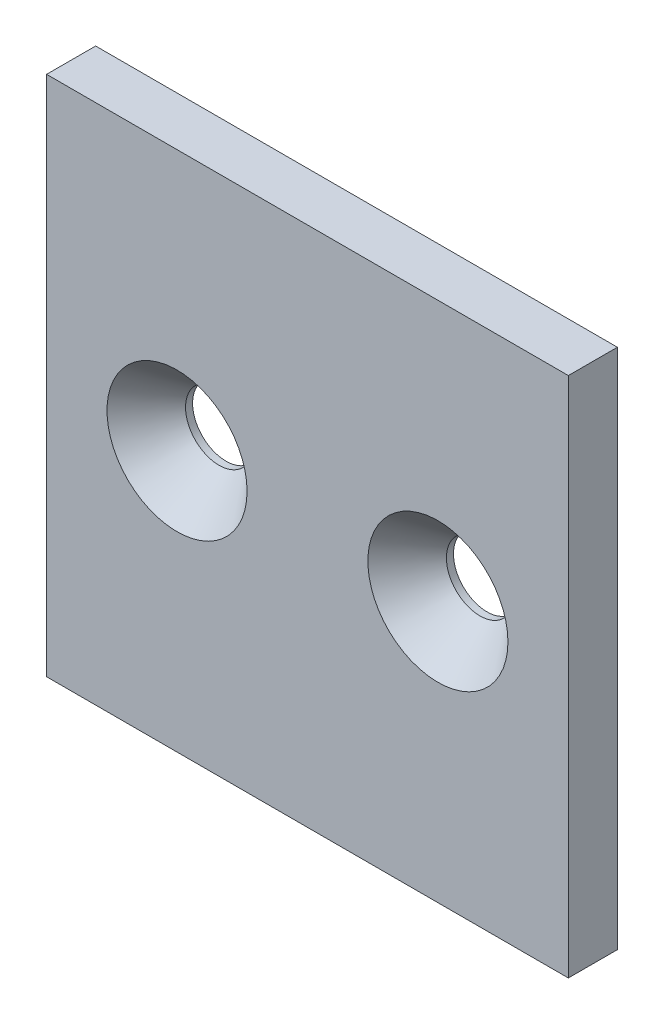
from build123d import *

# Parameters (mm, degrees)
SKETCH1_W           = 50.8
SKETCH1_H           = 50.8
SKETCH1_R           = 3.2639
BOSS_EXTRUDE1_DEPTH = 2.3876
CUT_EXTRUDE1_START  = -4.0894
SKETCH2_R           = 3.2639
CUT_EXTRUDE1_DEPTH  = 5.0894
CUT_EXTRUDE1_TAPER  = -41


with BuildPart() as part:
    # Sketch1 → Boss-Extrude1 (new body, symmetric)
    with BuildSketch(Plane.XY):
        with Locations((25.4, 25.4)):
            Rectangle(SKETCH1_W, SKETCH1_H)
        with Locations((12.7, 25.4)):
            Circle(SKETCH1_R, mode=Mode.SUBTRACT)
        with Locations((38.1, 25.4)):
            Circle(SKETCH1_R, mode=Mode.SUBTRACT)
    extrude(amount=BOSS_EXTRUDE1_DEPTH, both=True)

    # Sketch2 → Cut-Extrude1 (cut, through all)
    with BuildSketch(Plane.XY.offset(2.3876).offset(CUT_EXTRUDE1_START)):
        with Locations((12.7, 25.4)):
            Circle(SKETCH2_R)
        with Locations((38.1, 25.4)):
            Circle(SKETCH2_R)
    extrude(amount=CUT_EXTRUDE1_DEPTH, taper=CUT_EXTRUDE1_TAPER, mode=Mode.SUBTRACT)


solid = part.part
